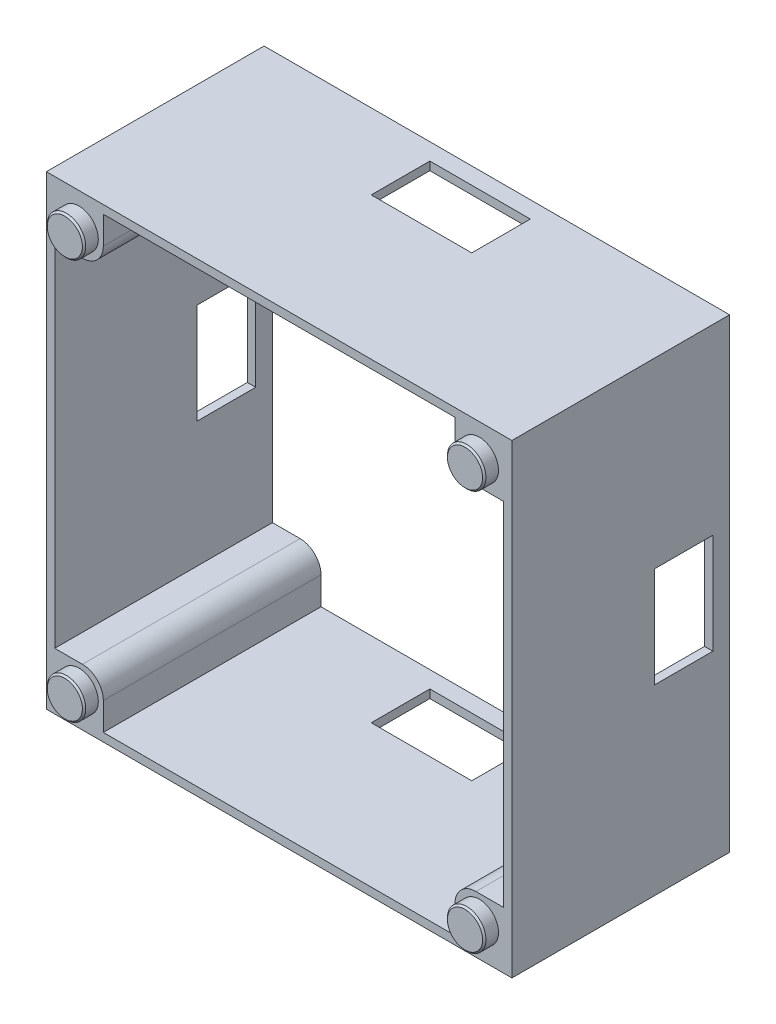
from build123d import *

# Parameters (mm, degrees)
SKICA1_W                 = 5.8
SKICA1_H                 = 5.8
SKICA1_W_2               = 1
SKICA1_H_2               = 42
SKICA1_W_3               = 42
SKICA1_H_3               = 1
P_IDAT_VYSUNUT_M2_DEPTH  = 26
ZAOBLIT1_R               = 2.5
SKICA2_R                 = 2.4
ODEBRAT_VYSUNUT_M1_DEPTH = 1.9
SKICA3_R                 = 2.3
P_IDAT_VYSUNUT_M3_DEPTH  = 1.7
ZKOSEN_1_SIZE            = 0.2
SKICA4_W                 = 12
SKICA4_H                 = 7
ODEBRAT_VYSUNUT_M2_DEPTH = 68.7
SKICA5_W                 = 7
SKICA5_H                 = 12
ODEBRAT_VYSUNUT_M3_DEPTH = 55.6


with BuildPart() as part:
    # Skica1 → Přidat vysunutím2 (new body)
    with BuildSketch(Plane.XY):
        Polygon((-27.8, 27.8), (-27.8, 21), (-26.8, 21), (-26.8, 26.8), (-21, 26.8), (-21, 27.8), align=None)
        with Locations((-23.9, 23.9)):
            Rectangle(SKICA1_W, SKICA1_H)
        Polygon((26.8, 21), (27.8, 21), (27.8, 27.8), (21, 27.8), (21, 26.8), (26.8, 26.8), align=None)
        with Locations((23.9, 23.9)):
            Rectangle(SKICA1_W, SKICA1_H)
        Polygon((21, -26.8), (21, -27.8), (27.8, -27.8), (27.8, -21), (26.8, -21), (26.8, -26.8), align=None)
        with Locations((23.9, -23.9)):
            Rectangle(SKICA1_W, SKICA1_H)
        with Locations((-23.9, -23.9)):
            Rectangle(SKICA1_W, SKICA1_H)
        Polygon((-27.8, -27.8), (-21, -27.8), (-21, -26.8), (-26.8, -26.8), (-26.8, -21), (-27.8, -21), align=None)
        with Locations((-27.3, 0)):
            Rectangle(SKICA1_W_2, SKICA1_H_2)
        with Locations((0, -27.3)):
            Rectangle(SKICA1_W_3, SKICA1_H_3)
        with Locations((27.3, 0)):
            Rectangle(SKICA1_W_2, SKICA1_H_2)
        with Locations((0, 27.3)):
            Rectangle(SKICA1_W_3, SKICA1_H_3)
    extrude(amount=P_IDAT_VYSUNUT_M2_DEPTH)

    # Zaoblit1
    zaoblit1_edges = [part.edges().sort_by_distance(p)[0] for p in [
        (21, -21, 13),
        (21, 21, 13),
        (-21, 21, 13),
        (-21, -21, 13),
    ]]
    fillet(zaoblit1_edges, radius=ZAOBLIT1_R)

    # Skica2 → Odebrat vysunutím1 (cut)
    with BuildSketch(Plane(origin=(0, 0, 0), x_dir=(-1, 0, 0), z_dir=(0, 0, -1))):
        with Locations((-23.9, 23.9)):
            Circle(SKICA2_R)
        with Locations((23.9, 23.9)):
            Circle(SKICA2_R)
        with Locations((23.9, -23.9)):
            Circle(SKICA2_R)
        with Locations((-23.9, -23.9)):
            Circle(SKICA2_R)
    extrude(amount=-ODEBRAT_VYSUNUT_M1_DEPTH, mode=Mode.SUBTRACT)

    # Skica3 → Přidat vysunutím3 (add)
    with BuildSketch(Plane.XY.offset(26)):
        with Locations((-23.9, 23.9)):
            Circle(SKICA3_R)
        with Locations((23.9, 23.9)):
            Circle(SKICA3_R)
        with Locations((23.9, -23.9)):
            Circle(SKICA3_R)
        with Locations((-23.9, -23.9)):
            Circle(SKICA3_R)
    extrude(amount=P_IDAT_VYSUNUT_M3_DEPTH)

    # Zkosení1
    zkosen_1_edges = [part.edges().sort_by_distance(p)[0] for p in [
        (-26.2, 23.9, 27.7),
        (21.6, 23.9, 27.7),
        (21.6, -23.9, 27.7),
        (-26.2, -23.9, 27.7),
    ]]
    chamfer(zkosen_1_edges, length=ZKOSEN_1_SIZE)

    # Skica4 → Odebrat vysunutím2 (cut)
    with BuildSketch(Plane(origin=(0, -27.8, 0), x_dir=(-1, 0, 0), z_dir=(0, -1, 0))):
        with Locations((0, -5.5)):
            Rectangle(SKICA4_W, SKICA4_H)
    extrude(amount=-ODEBRAT_VYSUNUT_M2_DEPTH, mode=Mode.SUBTRACT)

    # Skica5 → Odebrat vysunutím3 (cut)
    with BuildSketch(Plane.ZY.offset(27.8)):
        with Locations((5.5, 0)):
            Rectangle(SKICA5_W, SKICA5_H)
    extrude(amount=-ODEBRAT_VYSUNUT_M3_DEPTH, mode=Mode.SUBTRACT)


solid = part.part
